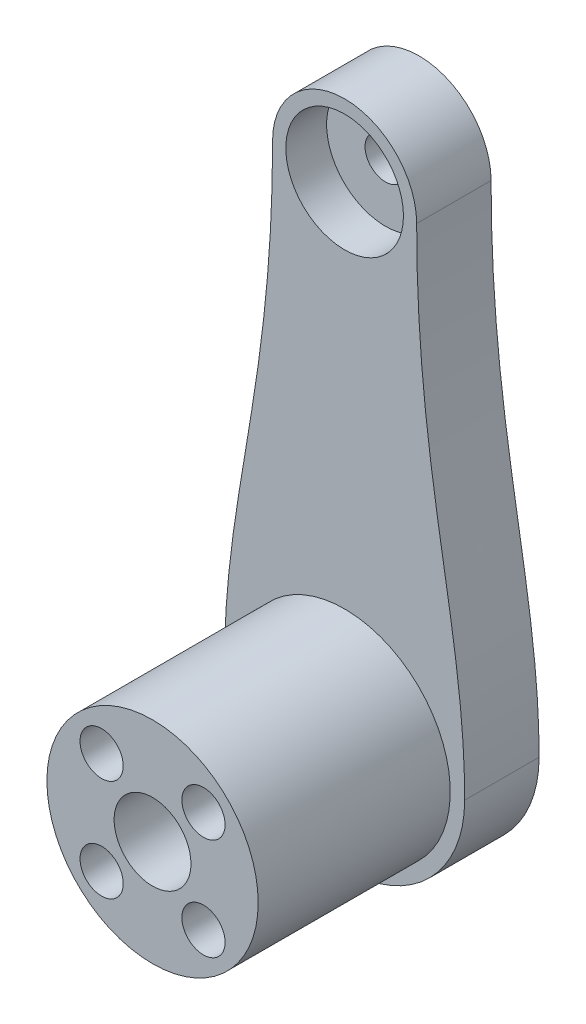
from build123d import *

# Parameters (mm, degrees)
BOSS_EXTRUDE1_DEPTH = 7.75
SKETCH2_R           = 6.125
CUT_EXTRUDE1_DEPTH  = 4.25
CUT_EXTRUDE2_REACH  = 5.5
SKETCH3_R           = 2.125
SKETCH4_R           = 11
BOSS_EXTRUDE2_DEPTH = 20
SKETCH5_R           = 2.25
SKETCH5_R_2         = 4
CUT_EXTRUDE3_DEPTH  = 10
SKETCH6_R           = 2.125
CUT_EXTRUDE4_DEPTH  = 28.75
SKETCH10_R          = 2.75
CUT_EXTRUDE5_DEPTH  = 6


with BuildPart() as part:
    # Sketch1 → Boss-Extrude1 (new body)
    with BuildSketch(Plane.XY):
        with BuildLine():
            ThreePointArc((-12.5, 0), (0, -12.5), (12.5, 0))
            add(Edge.make_bspline(
                [(7.5, 49.5), (7.5, 26.668276539), (12.5, 15.631461909), (12.5, 0)],
                knots=[0, 0, 0, 0, 1, 1, 1, 1], degree=3))
            ThreePointArc((7.5, 49.5), (0, 57), (-7.5, 49.5))
            add(Edge.make_bspline(
                [(-7.5, 49.5), (-7.5, 26.668276539), (-12.5, 15.631461909), (-12.5, 0)],
                knots=[0, 0, 0, 0, 1, 1, 1, 1], degree=3))
        make_face()
    extrude(amount=BOSS_EXTRUDE1_DEPTH)

    # Sketch2 → Cut-Extrude1 (cut)
    with BuildSketch(Plane.XY.offset(7.75)):
        with Locations((0, 49.5)):
            Circle(SKETCH2_R)
    extrude(amount=-CUT_EXTRUDE1_DEPTH, mode=Mode.SUBTRACT)

    # Sketch3 → Cut-Extrude2 (cut, up to next)
    with BuildSketch(Plane.XY.offset(3.5), mode=Mode.PRIVATE) as cut_extrude2_sk1:
        with Locations((0, 49.5)):
            Circle(SKETCH3_R)
    cut_extrude2_tool1 = extrude(cut_extrude2_sk1.sketch, amount=-CUT_EXTRUDE2_REACH, mode=Mode.PRIVATE) & part.part
    add(cut_extrude2_tool1.solids().sort_by_distance((0, 49.5, 3.5))[0], mode=Mode.SUBTRACT)

    # Sketch4 → Boss-Extrude2 (add)
    with BuildSketch(Plane.XY.offset(7.75)):
        Circle(SKETCH4_R)
    extrude(amount=BOSS_EXTRUDE2_DEPTH)

    # Sketch5 → Cut-Extrude3 (cut)
    with BuildSketch(Plane.XY.offset(27.75)):
        with Locations((5.303300859, 5.303300859)):
            Circle(SKETCH5_R)
        with Locations((5.303300859, -5.303300859)):
            Circle(SKETCH5_R)
        with Locations((-5.303300859, -5.303300859)):
            Circle(SKETCH5_R)
        with Locations((-5.303300859, 5.303300859)):
            Circle(SKETCH5_R)
        Circle(SKETCH5_R_2)
    extrude(amount=-CUT_EXTRUDE3_DEPTH, mode=Mode.SUBTRACT)

    # Sketch6 → Cut-Extrude4 (cut, through all)
    with BuildSketch(Plane(origin=(0, 0, 0), x_dir=(-1, 0, 0), z_dir=(0, 0, -1))):
        Circle(SKETCH6_R)
    extrude(amount=-CUT_EXTRUDE4_DEPTH, mode=Mode.SUBTRACT)

    # Sketch10 → Cut-Extrude5 (cut)
    with BuildSketch(Plane(origin=(0, 0, 0), x_dir=(-1, 0, 0), z_dir=(0, 0, -1))):
        Circle(SKETCH10_R)
    extrude(amount=-CUT_EXTRUDE5_DEPTH, mode=Mode.SUBTRACT)


solid = part.part
